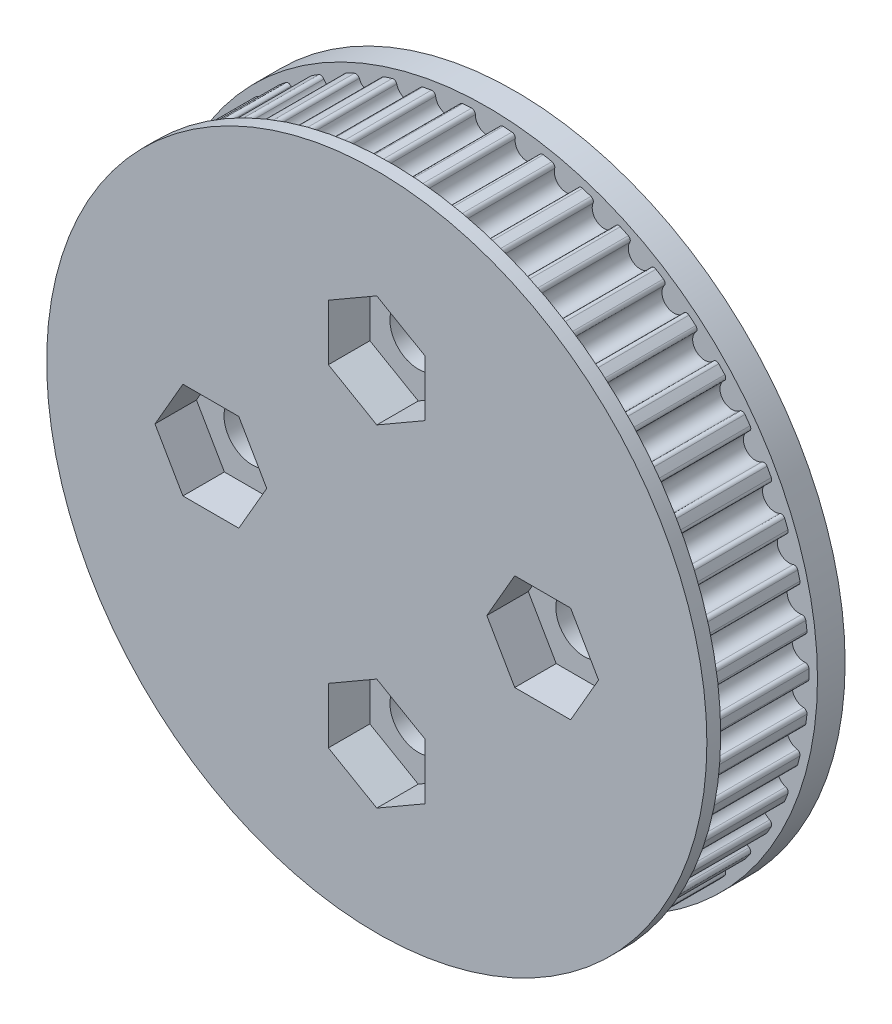
from build123d import *

# Parameters (mm, degrees)
BOSS_EXTRUDE2_DEPTH      = 3.5
FILLET2_R                = 0.26
CIRPATTERN6_COUNT        = 50
FILLET2_OF_CIRPATTERN6_R = 0.26
SKETCH2_R                = 23.875
BOSS_EXTRUDE3_DEPTH      = 1
SKETCH2_6_R              = 2.05
CUT_EXTRUDE4_DEPTH       = 2
SKETCH2_7_R              = 2.05
CUT_EXTRUDE5_DEPTH       = 7
BOSS_EXTRUDE4_START      = -7
SKETCH2_8_R              = 23.875
SKETCH2_8_R_2            = 2.05
BOSS_EXTRUDE4_DEPTH      = 2
SKETCH5_R                = 16.25
CUT_EXTRUDE6_DEPTH       = 3


with BuildPart() as part:
    # Sketch1 → Boss-Extrude2 (new body, symmetric)
    with BuildSketch(Plane(origin=(0, 0, 0), x_dir=(0, 1, 0), z_dir=(0, 0, 1))):
        with BuildLine():
            Line((0, 0), (0, 23.258241464))
            ThreePointArc((0, 23.258241464), (0.319668882, 23.256044543), (0.639277374, 23.249454196))
            ThreePointArc((0.639277374, 23.249454196), (1.386932157, 22.044655365), (2.279692792, 23.146248006))
            ThreePointArc((2.279692792, 23.146248006), (2.597607065, 23.11272882), (2.91503061, 23.074843283))
            Line((2.91503061, 23.074843283), (0, 0))
        make_face()
    boss_extrude2 = extrude(amount=BOSS_EXTRUDE2_DEPTH, both=True)

    # Fillet2
    fillet2_edges = [part.edges().sort_by_distance(p)[0] for p in [
        (-23.146248006, 2.279692792, 0),
        (-23.249454196, 0.639277374, 0),
    ]]
    fillet(fillet2_edges, radius=FILLET2_R)

    # CirPattern6: Boss-Extrude2 ×50 about axis
    cirpattern6_axis = Axis((0, 0, 0), (0, 0, 1))
    for i in range(1, CIRPATTERN6_COUNT):
        add(boss_extrude2.rotate(cirpattern6_axis, i * 360 / CIRPATTERN6_COUNT))

    # Fillet2 of CirPattern6
    fillet2_of_cirpattern6_edges = [part.edges().sort_by_distance(p)[0] for p in [
        (-23.249454196, -0.639277374, 0),
        (-23.146248006, -2.279692792, 0),
        (-22.986002605, -3.548165754, 0),
        (-22.678011658, -5.162710841, 0),
        (-22.360048022, -6.40109744, 0),
        (-21.852129519, -7.964309856, 0),
        (-21.381462124, -9.153079997, 0),
        (-20.681626243, -10.640306947, 0),
        (-20.065677796, -11.760713013, 0),
        (-19.184961367, -13.148500041, 0),
        (-18.433445742, -14.18287256, 0),
        (-17.38573819, -15.449333435, 0),
        (-16.510507238, -16.381359734, 0),
        (-15.312331536, -17.506521611, 0),
        (-14.327188171, -18.32150308, 0),
        (-12.997440266, -19.287621484, 0),
        (-11.917920788, -19.972705377, 0),
        (-10.477571599, -20.764544044, 0),
        (-9.320700675, -21.308926179, 0),
        (-7.792465369, -21.913997341, 0),
        (-6.576487544, -22.309092486, 0),
        (-4.984467305, -22.717853809, 0),
        (-3.728559277, -22.957431078, 0),
        (-2.097861214, -23.163436151, 0),
        (-0.821829402, -23.243717268, 0),
        (0.821829402, -23.243717268, 0),
        (2.097861214, -23.163436151, 0),
        (3.728559277, -22.957431078, 0),
        (4.984467305, -22.717853809, 0),
        (6.576487544, -22.309092486, 0),
        (7.792465369, -21.913997341, 0),
        (9.320700675, -21.308926179, 0),
        (10.477571599, -20.764544044, 0),
        (11.917920788, -19.972705377, 0),
        (12.997440266, -19.287621484, 0),
        (14.327188171, -18.32150308, 0),
        (15.312331536, -17.506521611, 0),
        (16.510507238, -16.381359734, 0),
        (17.38573819, -15.449333435, 0),
        (18.433445742, -14.18287256, 0),
        (19.184961367, -13.148500041, 0),
        (20.065677796, -11.760713013, 0),
        (20.681626243, -10.640306947, 0),
        (21.381462124, -9.153079997, 0),
        (21.852129519, -7.964309856, 0),
        (22.360048022, -6.40109744, 0),
        (22.678011658, -5.162710841, 0),
        (22.986002605, -3.548165754, 0),
        (23.146248006, -2.279692792, 0),
        (23.249454196, -0.639277374, 0),
        (23.249454196, 0.639277374, 0),
        (23.146248006, 2.279692792, 0),
        (22.986002605, 3.548165754, 0),
        (22.678011658, 5.162710841, 0),
        (22.360048022, 6.40109744, 0),
        (21.852129519, 7.964309856, 0),
        (21.381462124, 9.153079997, 0),
        (20.681626243, 10.640306947, 0),
        (20.065677796, 11.760713013, 0),
        (19.184961367, 13.148500041, 0),
        (18.433445742, 14.18287256, 0),
        (17.38573819, 15.449333435, 0),
        (16.510507238, 16.381359734, 0),
        (15.312331536, 17.506521611, 0),
        (14.327188171, 18.32150308, 0),
        (12.997440266, 19.287621484, 0),
        (11.917920788, 19.972705377, 0),
        (10.477571599, 20.764544044, 0),
        (9.320700675, 21.308926179, 0),
        (7.792465369, 21.913997341, 0),
        (6.576487544, 22.309092486, 0),
        (4.984467305, 22.717853809, 0),
        (3.728559277, 22.957431078, 0),
        (2.097861214, 23.163436151, 0),
        (0.821829402, 23.243717268, 0),
        (-0.821829402, 23.243717268, 0),
        (-2.097861214, 23.163436151, 0),
        (-3.728559277, 22.957431078, 0),
        (-4.984467305, 22.717853809, 0),
        (-6.576487544, 22.309092486, 0),
        (-7.792465369, 21.913997341, 0),
        (-9.320700675, 21.308926179, 0),
        (-10.477571599, 20.764544044, 0),
        (-11.917920788, 19.972705377, 0),
        (-12.997440266, 19.287621484, 0),
        (-14.327188171, 18.32150308, 0),
        (-15.312331536, 17.506521611, 0),
        (-16.510507238, 16.381359734, 0),
        (-17.38573819, 15.449333435, 0),
        (-18.433445742, 14.18287256, 0),
        (-19.184961367, 13.148500041, 0),
        (-20.065677796, 11.760713013, 0),
        (-20.681626243, 10.640306947, 0),
        (-21.381462124, 9.153079997, 0),
        (-21.852129519, 7.964309856, 0),
        (-22.360048022, 6.40109744, 0),
        (-22.678011658, 5.162710841, 0),
        (-22.986002605, 3.548165754, 0),
    ]]
    fillet(fillet2_of_cirpattern6_edges, radius=FILLET2_OF_CIRPATTERN6_R)

    # Sketch2 → Boss-Extrude3 (add)
    with BuildSketch(Plane.XY.offset(3.5)):
        Circle(SKETCH2_R)
        Polygon((3.5, 14.020725942), (0, 16.041451884), (-3.5, 14.020725942), (-3.5, 9.979274058), (0, 7.958548116), (3.5, 9.979274058), align=None, mode=Mode.SUBTRACT)
        Polygon((14.020725942, -3.5), (16.041451884, 0), (14.020725942, 3.5), (9.979274058, 3.5), (7.958548116, 0), (9.979274058, -3.5), align=None, mode=Mode.SUBTRACT)
        Polygon((-3.5, -14.020725942), (0, -16.041451884), (3.5, -14.020725942), (3.5, -9.979274058), (0, -7.958548116), (-3.5, -9.979274058), align=None, mode=Mode.SUBTRACT)
        Polygon((-14.020725942, 3.5), (-16.041451884, 0), (-14.020725942, -3.5), (-9.979274058, -3.5), (-7.958548116, 0), (-9.979274058, 3.5), align=None, mode=Mode.SUBTRACT)
    extrude(amount=BOSS_EXTRUDE3_DEPTH)

    # Sketch2_6 → Cut-Extrude4 (cut)
    with BuildSketch(Plane.XY.offset(3.5)):
        Polygon((-3.5, -9.979274058), (-3.5, -14.020725942), (0, -16.041451884), (3.5, -14.020725942), (3.5, -9.979274058), (0, -7.958548116), align=None)
        with Locations((0, -12)):
            Circle(SKETCH2_6_R, mode=Mode.SUBTRACT)
        Polygon((9.979274058, -3.5), (14.020725942, -3.5), (16.041451884, 0), (14.020725942, 3.5), (9.979274058, 3.5), (7.958548116, 0), align=None)
        with Locations((12, 0)):
            Circle(SKETCH2_6_R, mode=Mode.SUBTRACT)
        Polygon((-9.979274058, 3.5), (-14.020725942, 3.5), (-16.041451884, 0), (-14.020725942, -3.5), (-9.979274058, -3.5), (-7.958548116, 0), align=None)
        with Locations((-12, 0)):
            Circle(SKETCH2_6_R, mode=Mode.SUBTRACT)
        Polygon((3.5, 9.979274058), (3.5, 14.020725942), (0, 16.041451884), (-3.5, 14.020725942), (-3.5, 9.979274058), (0, 7.958548116), align=None)
        with Locations((0, 12)):
            Circle(SKETCH2_6_R, mode=Mode.SUBTRACT)
    extrude(amount=-CUT_EXTRUDE4_DEPTH, mode=Mode.SUBTRACT)

    # Sketch2_7 → Cut-Extrude5 (cut)
    with BuildSketch(Plane.XY.offset(3.5)):
        with Locations((12, 0)):
            Circle(SKETCH2_7_R)
        with Locations((0, -12)):
            Circle(SKETCH2_7_R)
        with Locations((-12, 0)):
            Circle(SKETCH2_7_R)
        with Locations((0, 12)):
            Circle(SKETCH2_7_R)
    extrude(amount=-CUT_EXTRUDE5_DEPTH, mode=Mode.SUBTRACT)

    # Sketch2_8 → Boss-Extrude4 (add)
    with BuildSketch(Plane.XY.offset(3.5).offset(BOSS_EXTRUDE4_START)):
        Circle(SKETCH2_8_R)
        Polygon((3.5, 14.020725942), (0, 16.041451884), (-3.5, 14.020725942), (-3.5, 9.979274058), (0, 7.958548116), (3.5, 9.979274058), align=None, mode=Mode.SUBTRACT)
        Polygon((14.020725942, -3.5), (16.041451884, 0), (14.020725942, 3.5), (9.979274058, 3.5), (7.958548116, 0), (9.979274058, -3.5), align=None, mode=Mode.SUBTRACT)
        Polygon((-3.5, -14.020725942), (0, -16.041451884), (3.5, -14.020725942), (3.5, -9.979274058), (0, -7.958548116), (-3.5, -9.979274058), align=None, mode=Mode.SUBTRACT)
        Polygon((-14.020725942, 3.5), (-16.041451884, 0), (-14.020725942, -3.5), (-9.979274058, -3.5), (-7.958548116, 0), (-9.979274058, 3.5), align=None, mode=Mode.SUBTRACT)
        Polygon((3.5, 9.979274058), (3.5, 14.020725942), (0, 16.041451884), (-3.5, 14.020725942), (-3.5, 9.979274058), (0, 7.958548116), align=None)
        with Locations((0, 12)):
            Circle(SKETCH2_8_R_2, mode=Mode.SUBTRACT)
        Polygon((9.979274058, -3.5), (14.020725942, -3.5), (16.041451884, 0), (14.020725942, 3.5), (9.979274058, 3.5), (7.958548116, 0), align=None)
        with Locations((12, 0)):
            Circle(SKETCH2_8_R_2, mode=Mode.SUBTRACT)
        Polygon((-3.5, -9.979274058), (-3.5, -14.020725942), (0, -16.041451884), (3.5, -14.020725942), (3.5, -9.979274058), (0, -7.958548116), align=None)
        with Locations((0, -12)):
            Circle(SKETCH2_8_R_2, mode=Mode.SUBTRACT)
        Polygon((-9.979274058, 3.5), (-14.020725942, 3.5), (-16.041451884, 0), (-14.020725942, -3.5), (-9.979274058, -3.5), (-7.958548116, 0), align=None)
        with Locations((-12, 0)):
            Circle(SKETCH2_8_R_2, mode=Mode.SUBTRACT)
    extrude(amount=-BOSS_EXTRUDE4_DEPTH)

    # Sketch5 → Cut-Extrude6 (cut)
    with BuildSketch(Plane(origin=(0, 0, -5.5), x_dir=(1, 0, 0), z_dir=(0, 0, -1))):
        Circle(SKETCH5_R)
    extrude(amount=-CUT_EXTRUDE6_DEPTH, mode=Mode.SUBTRACT)


solid = part.part
